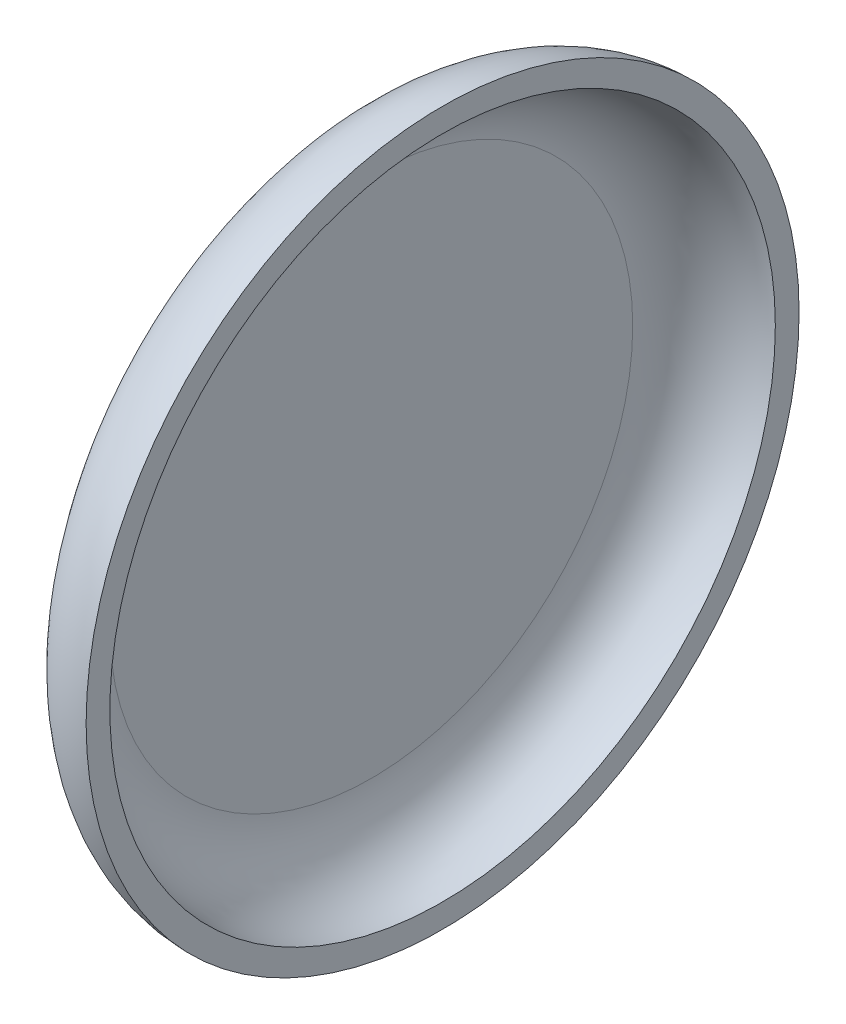
from build123d import *


with BuildPart() as part:
    # Sketch1 → Revolve1 (revolve)
    with BuildSketch(Plane.XY):
        with BuildLine():
            Line((-3, 11), (-3, 0))
            Line((-3, 0), (-4, 0))
            Line((-4, 0), (-4, 11))
            ThreePointArc((-4, 11), (-2.828427125, 13.828427125), (0, 15))
            Line((0, 15), (0, 14))
            ThreePointArc((0, 14), (-2.121320344, 13.121320344), (-3, 11))
        make_face()
    revolve(axis=Axis((0, 0, 0), (-1, 0, 0)))


solid = part.part
